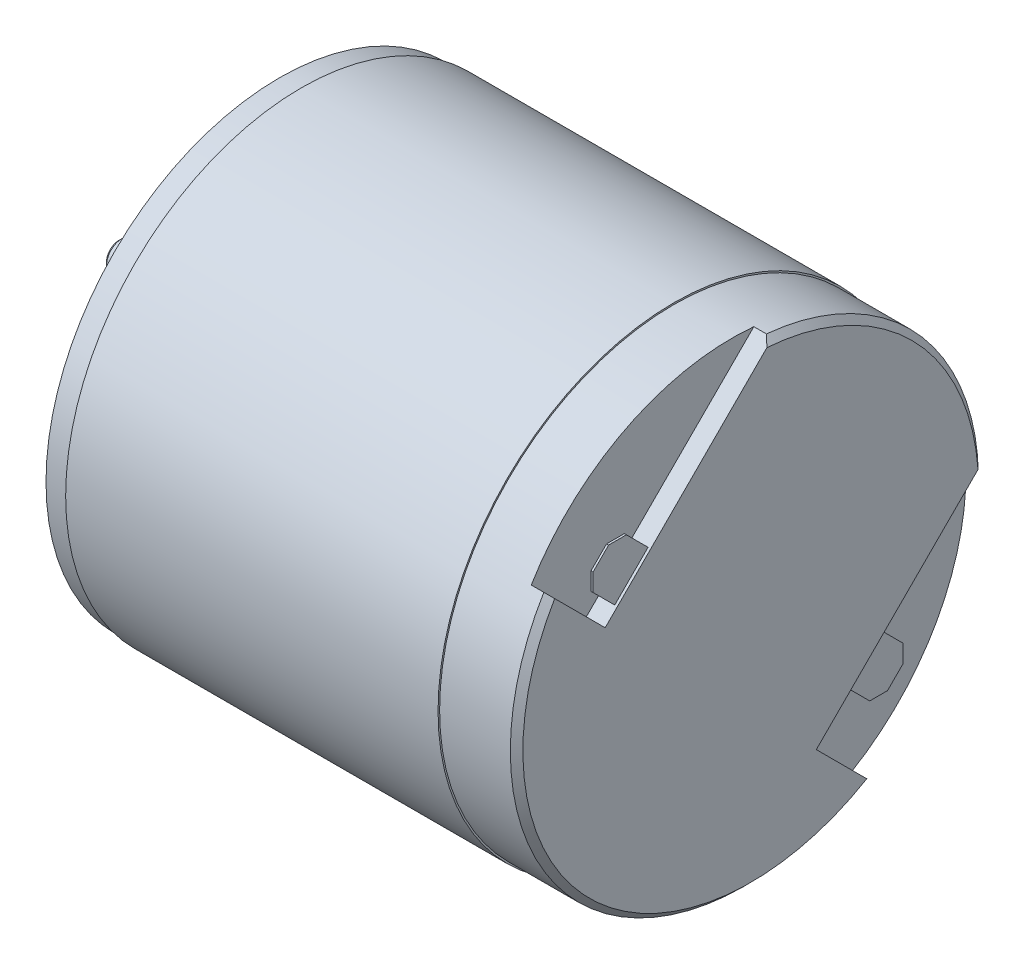
from build123d import *

# Parameters (mm, degrees)
ENL_V_MAT_EXTRU_2_DEPTH = 1.2
CHANFREIN1_SIZE         = 0.2
EXTRUSION1_DEPTH        = 0.13
CHANFREIN2_SIZE         = 0.8
CHANFREIN3_SIZE         = 0.4
CHANFREIN4_SIZE         = 0.2
CHANFREIN4_SIZE2        = 0.115470054


with BuildPart() as part:
    # Esquisse1 → Révolution1 (revolve)
    with BuildSketch(Plane.XY, mode=Mode.PRIVATE) as r_volution1_sk:
        Polygon((0, 0), (0, 14.9), (-4.9, 14.9), (-4.9, 15), (-28.6, 15), (-28.6, 14.85), (-30, 14.85), (-30, 4), (-30.9, 4), (-30.9, 2.1), (-32, 2.1), (-32, 1), (-40.2, 1), (-40.2, 0), align=None)
    revolve(r_volution1_sk.sketch.rotate(Axis((0, 0, 0), (1, 0, 0)), 90), axis=Axis((0, 0, 0), (1, 0, 0)))  # turned: the seam where the file's is

    # Esquisse2 → Enlèv. mat.-Extru.2 (cut)
    with BuildSketch(Plane(origin=(0, 0, 0), x_dir=(0, 0, -1), z_dir=(1, 0, 0))):
        with BuildLine():
            Line((-9.263098834, 4.171930009), (1.399135134, 14.834163976))
            ThreePointArc((1.399135134, 14.834163976), (-6.717323093, 13.299908664), (-12.769331279, 7.678162455))
            Line((-12.769331279, 7.678162455), (-9.263098834, 4.171930009))
        make_face()
        with BuildLine():
            ThreePointArc((14.9, 0), (14.883531893, 0.700341614), (14.834163976, 1.399135134))
            Line((14.834163976, 1.399135134), (4.171930009, -9.263098834))
            Line((4.171930009, -9.263098834), (7.678162455, -12.769331279))
            ThreePointArc((7.678162455, -12.769331279), (12.969476099, -7.335031678), (14.9, 0))
        make_face()
    extrude(amount=-ENL_V_MAT_EXTRU_2_DEPTH, mode=Mode.SUBTRACT)

    # Chanfrein1
    chanfrein1_edges = [part.edges().sort_by_distance(p)[0] for p in [
        (-40.2, 0, -1),
    ]]
    chamfer(chanfrein1_edges, length=CHANFREIN1_SIZE)

    # Esquisse3 → Extrusion1 (add)
    with BuildSketch(Plane(origin=(-0.3, 0, 0), x_dir=(0, 0, -1), z_dir=(1, 0, 0))):
        Polygon((-6.363961031, 7.071067812), (-8.308504679, 9.01561146), (-10.429825023, 6.894291117), (-8.485281374, 4.949747468), align=None)
        Polygon((8.485281374, -4.949747468), (6.363961031, -7.071067812), (8.308504679, -9.01561146), (10.429825023, -6.894291117), align=None)
    extrude(amount=EXTRUSION1_DEPTH)

    # Chanfrein2
    chanfrein2_edges = [part.edges().sort_by_distance(p)[0] for p in [
        (-0.235, 9.01561146, 8.308504679),
        (-0.235, 6.894291117, 10.429825023),
        (-0.235, -6.894291117, -10.429825023),
        (-0.235, -9.01561146, -8.308504679),
    ]]
    chamfer(chanfrein2_edges, length=CHANFREIN2_SIZE)

    # Chanfrein3
    chanfrein3_edges = [part.edges().sort_by_distance(p)[0] for p in [
        (0, 10.53589104, -10.53589104),
        (0, -12.969476099, 7.335031678),
    ]]
    chamfer(chanfrein3_edges, length=CHANFREIN3_SIZE)

    # Chanfrein4
    chanfrein4_edges = [part.edges().sort_by_distance(p)[0] for p in [
        (-32, 0, -2.1),
    ]]
    chanfrein4_side = [part.faces().sort_by_distance(p)[0] for p in [
        (-31.45, 0, -2.1),
    ]]
    chamfer(chanfrein4_edges, length=CHANFREIN4_SIZE, length2=CHANFREIN4_SIZE2, reference=chanfrein4_side[0])


solid = part.part
